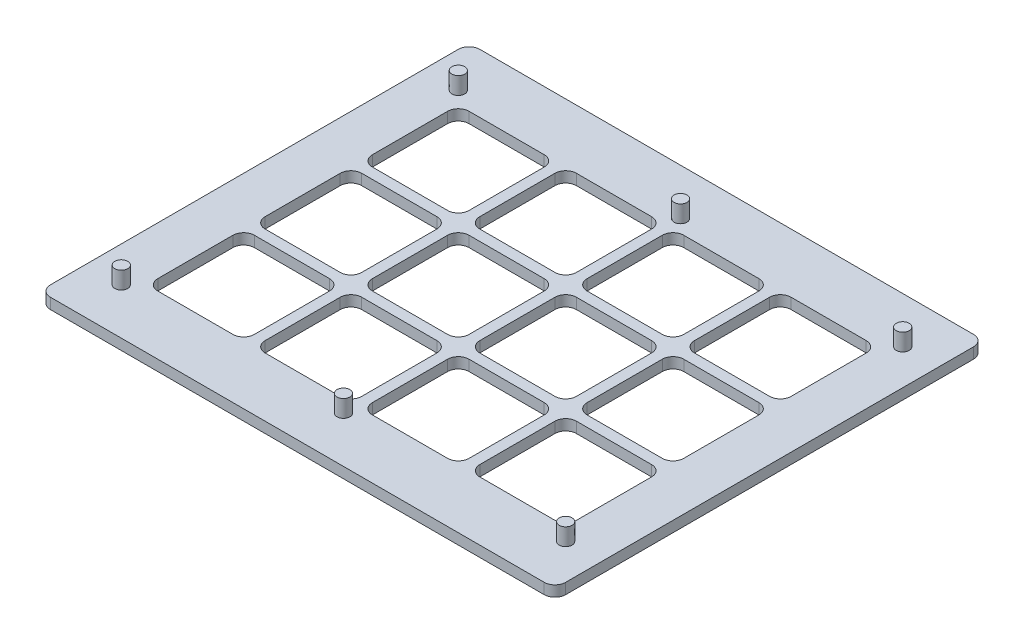
from build123d import *

# Parameters (mm, degrees)
SKETCH1_W               = 60.96
SKETCH1_H               = 50.8
BOSS_EXTRUDE1_DEPTH     = 1.27
SKETCH2_W               = 11.43
SKETCH2_H               = 11.43
CUT_EXTRUDE1_DEPTH      = 2.27
FILLET2_R               = 1.27
SKETCH4_R               = 0.762
BOSS_EXTRUDE2_DEPTH     = 2.032
FILLET3_R               = 1.27
LPATTERN13_COUNT        = 4
LPATTERN13_PITCH        = 12.7
LPATTERN13_COUNT_DIR2   = 3
LPATTERN13_PITCH_DIR2   = 12.7
FILLET2_OF_LPATTERN13_R = 1.27
LPATTERN14_COUNT        = 3
LPATTERN14_PITCH        = 26.289
LPATTERN14_COUNT_DIR2   = 3
LPATTERN14_PITCH_DIR2   = 39.878


with BuildPart() as part:
    # Sketch1 → Boss-Extrude1 (new body)
    with BuildSketch(Plane(origin=(0, 0, 0), x_dir=(1, 0, 0), z_dir=(0, 1, 0))):
        Rectangle(SKETCH1_W, SKETCH1_H)
    extrude(amount=BOSS_EXTRUDE1_DEPTH)

    # Sketch2 → Cut-Extrude1 (cut, through all)
    with BuildSketch(Plane(origin=(0, 1.27, 0), x_dir=(1, 0, 0), z_dir=(0, 1, 0))):
        with Locations((-19.05, 12.7)):
            Rectangle(SKETCH2_W, SKETCH2_H)
    cut_extrude1 = extrude(amount=-CUT_EXTRUDE1_DEPTH, mode=Mode.SUBTRACT)

    # Fillet2
    fillet2_edges = [part.edges().sort_by_distance(p)[0] for p in [
        (-13.335, 0.635, -18.415),
        (-13.335, 0.635, -6.985),
        (-24.765, 0.635, -6.985),
        (-24.765, 0.635, -18.415),
    ]]
    fillet(fillet2_edges, radius=FILLET2_R)

    # Sketch4 → Boss-Extrude2 (add)
    with BuildSketch(Plane(origin=(0, 1.27, 0), x_dir=(1, 0, 0), z_dir=(0, 1, 0))):
        with Locations((-26.289, 19.939)):
            Circle(SKETCH4_R)
    boss_extrude2 = extrude(amount=BOSS_EXTRUDE2_DEPTH)

    # Fillet3
    fillet3_edges = [part.edges().sort_by_distance(p)[0] for p in [
        (-30.48, 0.635, -25.4),
        (30.48, 0.635, -25.4),
        (30.48, 0.635, 25.4),
        (-30.48, 0.635, 25.4),
    ]]
    fillet(fillet3_edges, radius=FILLET3_R)

    # LPattern13: Cut-Extrude1 4 × 3
    with Locations(*[(i * LPATTERN13_PITCH, 0, j * LPATTERN13_PITCH_DIR2) for i in range(LPATTERN13_COUNT) for j in range(LPATTERN13_COUNT_DIR2) if (i, j) != (0, 0)]):
        add(cut_extrude1, mode=Mode.SUBTRACT)

    # Fillet2 of LPattern13
    fillet2_of_lpattern13_edges = [part.edges().sort_by_distance(p)[0] for p in [
        (-13.335, 0.635, -5.715),
        (-13.335, 0.635, 5.715),
        (-24.765, 0.635, 5.715),
        (-24.765, 0.635, -5.715),
        (-13.335, 0.635, 6.985),
        (-13.335, 0.635, 18.415),
        (-24.765, 0.635, 18.415),
        (-24.765, 0.635, 6.985),
        (-0.635, 0.635, -18.415),
        (-0.635, 0.635, -6.985),
        (-12.065, 0.635, -6.985),
        (-12.065, 0.635, -18.415),
        (-0.635, 0.635, -5.715),
        (-0.635, 0.635, 5.715),
        (-12.065, 0.635, 5.715),
        (-12.065, 0.635, -5.715),
        (-0.635, 0.635, 6.985),
        (-0.635, 0.635, 18.415),
        (-12.065, 0.635, 18.415),
        (-12.065, 0.635, 6.985),
        (12.065, 0.635, -18.415),
        (12.065, 0.635, -6.985),
        (0.635, 0.635, -6.985),
        (0.635, 0.635, -18.415),
        (12.065, 0.635, -5.715),
        (12.065, 0.635, 5.715),
        (0.635, 0.635, 5.715),
        (0.635, 0.635, -5.715),
        (12.065, 0.635, 6.985),
        (12.065, 0.635, 18.415),
        (0.635, 0.635, 18.415),
        (0.635, 0.635, 6.985),
        (24.765, 0.635, -18.415),
        (24.765, 0.635, -6.985),
        (13.335, 0.635, -6.985),
        (13.335, 0.635, -18.415),
        (24.765, 0.635, -5.715),
        (24.765, 0.635, 5.715),
        (13.335, 0.635, 5.715),
        (13.335, 0.635, -5.715),
        (24.765, 0.635, 6.985),
        (24.765, 0.635, 18.415),
        (13.335, 0.635, 18.415),
        (13.335, 0.635, 6.985),
    ]]
    fillet(fillet2_of_lpattern13_edges, radius=FILLET2_OF_LPATTERN13_R)

    # LPattern14: Boss-Extrude2 3 × 3, 3 skipped
    with Locations(*[(i * LPATTERN14_PITCH, 0, j * LPATTERN14_PITCH_DIR2) for i in range(LPATTERN14_COUNT) for j in range(LPATTERN14_COUNT_DIR2) if (i, j) not in ((0, 0), (0, 2), (1, 2), (2, 2))]):
        add(boss_extrude2)


solid = part.part
